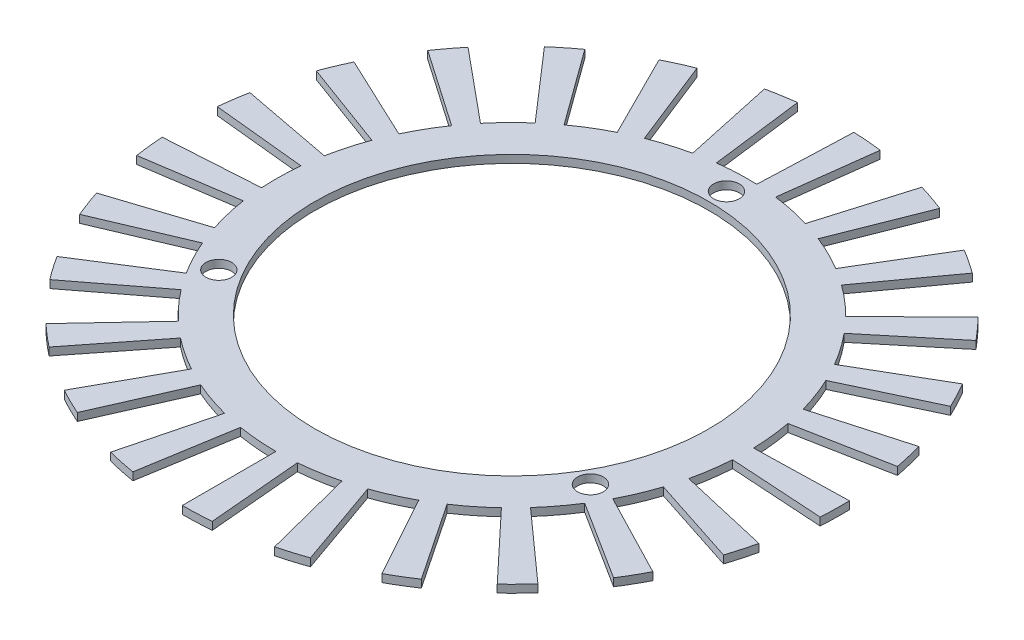
from build123d import *

# Parameters (mm, degrees)
SKETCH1_R           = 30.25
SKETCH1_R_2         = 25.25
EXTRUDE_THIN1_DEPTH = 1
SKETCH2_R           = 1.65
CUT_EXTRUDE3_DEPTH  = 10
BOSS_EXTRUDE1_DEPTH = 1


with BuildPart() as part:
    # Sketch1 → Extrude-Thin1 (new body)
    with BuildSketch(Plane(origin=(0, 0, 0), x_dir=(1, 0, 0), z_dir=(0, 1, 0))):
        Circle(SKETCH1_R)
        Circle(SKETCH1_R_2, mode=Mode.SUBTRACT)
    extrude(amount=-EXTRUDE_THIN1_DEPTH)

    # Sketch2 → Cut-Extrude3 (cut)
    with BuildSketch(Plane(origin=(0, 0, 0), x_dir=(1, 0, 0), z_dir=(0, 1, 0))):
        with Locations((0, 27.5)):
            Circle(SKETCH2_R)
        with Locations((23.815698604, -13.75)):
            Circle(SKETCH2_R)
        with Locations((-23.815698604, -13.75)):
            Circle(SKETCH2_R)
    extrude(amount=-CUT_EXTRUDE3_DEPTH, mode=Mode.SUBTRACT)

    # Sketch5 → Boss-Extrude1 (add)
    with BuildSketch(Plane.XZ.offset(1)):
        with BuildLine():
            Line((0, 42.25), (0, 30.25))
            ThreePointArc((0, 30.25), (1.319486468, 30.221208703), (2.636461218, 30.134889617))
            Line((2.636461218, 30.134889617), (3.682330131, 42.089225994))
            ThreePointArc((3.682330131, 42.089225994), (1.842919116, 42.209787362), (0, 42.25))
        make_face()
        with BuildLine():
            Line((10.507147733, 40.922638558), (7.522869087, 29.299640624))
            ThreePointArc((7.522869087, 29.299640624), (8.793741356, 28.943610918), (10.047874239, 28.532485403))
            Line((10.047874239, 28.532485403), (14.033807822, 39.851157298))
            ThreePointArc((14.033807822, 39.851157298), (12.28216768, 40.425373926), (10.507147733, 40.922638558))
        make_face()
        with BuildLine():
            Line((20.354092731, 37.023957232), (14.573048642, 26.508277071))
            ThreePointArc((14.573048642, 26.508277071), (15.715453134, 25.847379612), (16.827942369, 25.137280196))
            Line((16.827942369, 25.137280196), (23.503489755, 35.109093827))
            ThreePointArc((23.503489755, 35.109093827), (21.949682477, 36.100885573), (20.354092731, 37.023957232))
        make_face()
        with BuildLine():
            Line((28.922115225, 30.798924509), (20.707549954, 22.051300979))
            ThreePointArc((20.707549954, 22.051300979), (21.649705195, 21.127062384), (22.55064899, 20.162607225))
            Line((22.55064899, 20.162607225), (31.496360987, 28.160996868))
            ThreePointArc((31.496360987, 28.160996868), (30.238017999, 29.508045809), (28.922115225, 30.798924509))
        make_face()
        with BuildLine():
            Line((35.672854852, 22.638682088), (25.540919746, 16.208760548))
            ThreePointArc((25.540919746, 16.208760548), (26.223626655, 15.079254128), (26.8564154, 13.92104349))
            Line((26.8564154, 13.92104349), (37.510200022, 19.443440907))
            ThreePointArc((37.510200022, 19.443440907), (36.626387643, 21.061107005), (35.672854852, 22.638682088))
        make_face()
        with BuildLine():
            Line((40.182137813, 13.055968012), (28.769459618, 9.34776408))
            ThreePointArc((28.769459618, 9.34776408), (29.14982121, 8.083960876), (29.47469446, 6.804769394))
            Line((29.47469446, 6.804769394), (41.167135237, 9.504182046))
            ThreePointArc((41.167135237, 9.504182046), (40.713386648, 11.290821389), (40.182137813, 13.055968012))
        make_face()
        with BuildLine():
            Line((42.166629276, 2.65289945), (30.190308535, 1.899413216))
            ThreePointArc((30.190308535, 1.899413216), (30.244425292, 0.580722633), (30.240970066, -0.739073389))
            Line((30.240970066, -0.739073389), (42.237387943, -1.032259527))
            ThreePointArc((42.237387943, -1.032259527), (42.242213837, 0.811091941), (42.166629276, 2.65289945))
        make_face()
        with BuildLine():
            Line((41.501636343, -7.916860541), (29.714189335, -5.668284766))
            ThreePointArc((29.714189335, -5.668284766), (29.438660902, -6.95900455), (29.107094304, -8.236477473))
            Line((29.107094304, -8.236477473), (40.653710227, -11.503840437))
            ThreePointArc((40.653710227, -11.503840437), (41.116807375, -9.719601396), (41.501636343, -7.916860541))
        make_face()
        with BuildLine():
            Line((38.228942967, -17.989175069), (27.371018337, -12.87982357))
            ThreePointArc((27.371018337, -12.87982357), (26.783157179, -14.061471883), (26.144312759, -15.216353386))
            Line((26.144312759, -15.216353386), (36.515610383, -21.252592745))
            ThreePointArc((36.515610383, -21.252592745), (37.407880688, -19.639576432), (38.228942967, -17.989175069))
        make_face()
        with BuildLine():
            Line((32.554184507, -26.931163567), (23.308025594, -19.28207569))
            ThreePointArc((23.308025594, -19.28207569), (22.44476919, -20.280405224), (21.538787891, -21.240129853))
            Line((21.538787891, -21.240129853), (30.083100443, -29.665966489))
            ThreePointArc((30.083100443, -29.665966489), (31.348479281, -28.325524651), (32.554184507, -26.931163567))
        make_face()
        with BuildLine():
            Line((24.833926909, -34.180968012), (17.780503882, -24.47276408))
            ThreePointArc((17.780503882, -24.47276408), (16.696093806, -25.225046118), (15.579901766, -25.929310846))
            Line((15.579901766, -25.929310846), (21.760358665, -36.215318455))
            ThreePointArc((21.760358665, -36.215318455), (23.319337629, -35.231675982), (24.833926909, -34.180968012))
        make_face()
        with BuildLine():
            Line((15.553262351, -39.283056529), (11.135767719, -28.125738698))
            ThreePointArc((11.135767719, -28.125738698), (9.898341444, -28.584704593), (8.642073114, -28.989257878))
            Line((8.642073114, -28.989257878), (12.070333523, -40.489128771))
            ThreePointArc((12.070333523, -40.489128771), (13.824956232, -39.924091539), (15.553262351, -39.283056529))
        make_face()
        with BuildLine():
            Line((5.295329118, -41.916846131), (3.791330315, -30.011469715))
            ThreePointArc((3.791330315, -30.011469715), (2.478639886, -30.148280951), (1.161231225, -30.227703221))
            Line((1.161231225, -30.227703221), (1.621884934, -42.218858218))
            ThreePointArc((1.621884934, -42.218858218), (3.46190199, -42.107929593), (5.295329118, -41.916846131))
        make_face()
        with BuildLine():
            Line((-5.295329118, -41.916846131), (-3.791330315, -30.011469715))
            ThreePointArc((-3.791330315, -30.011469715), (-5.096803732, -29.81752994), (-6.392575093, -29.566830802))
            Line((-6.392575093, -29.566830802), (-8.92847265, -41.295821534))
            ThreePointArc((-8.92847265, -41.295821534), (-7.118676287, -41.645971569), (-5.295329118, -41.916846131))
        make_face()
        with BuildLine():
            Line((-15.553262351, -39.283056529), (-11.135767719, -28.125738698))
            ThreePointArc((-11.135767719, -28.125738698), (-12.351996427, -27.613233861), (-13.544712407, -27.048165664))
            Line((-13.544712407, -27.048165664), (-18.917821461, -37.778016506))
            ThreePointArc((-18.917821461, -37.778016506), (-17.251961951, -38.567243988), (-15.553262351, -39.283056529))
        make_face()
        with BuildLine():
            Line((-24.833926909, -34.180968012), (-17.780503882, -24.47276408))
            ThreePointArc((-17.780503882, -24.47276408), (-18.831067758, -23.673896745), (-19.845785627, -22.829964802))
            Line((-19.845785627, -22.829964802), (-27.718493975, -31.886479764))
            ThreePointArc((-27.718493975, -31.886479764), (-26.301243398, -33.065194627), (-24.833926909, -34.180968012))
        make_face()
        with BuildLine():
            Line((-32.554184507, -26.931163567), (-23.308025594, -19.28207569))
            ThreePointArc((-23.308025594, -19.28207569), (-24.126913847, -18.247041629), (-24.899875148, -17.177273288))
            Line((-24.899875148, -17.177273288), (-34.777511571, -23.991398228))
            ThreePointArc((-34.777511571, -23.991398228), (-33.697920993, -25.485537482), (-32.554184507, -26.931163567))
        make_face()
        with BuildLine():
            Line((-38.228942967, -17.989175069), (-27.371018337, -12.87982357))
            ThreePointArc((-27.371018337, -12.87982357), (-27.906777206, -11.67365778), (-28.389413938, -10.44527052))
            Line((-28.389413938, -10.44527052), (-39.651330212, -14.588848908))
            ThreePointArc((-39.651330212, -14.588848908), (-38.97723428, -16.304530288), (-38.228942967, -17.989175069))
        make_face()
        with BuildLine():
            Line((-41.501636343, -7.916860541), (-29.714189335, -5.668284766))
            ThreePointArc((-29.714189335, -5.668284766), (-29.933155119, -4.36677508), (-30.095141442, -3.05695299))
            Line((-30.095141442, -3.05695299), (-42.033709948, -4.269628556))
            ThreePointArc((-42.033709948, -4.269628556), (-41.807464588, -6.099049492), (-41.501636343, -7.916860541))
        make_face()
        with BuildLine():
            Line((-42.166629276, 2.65289945), (-30.190308535, 1.899413216))
            ThreePointArc((-30.190308535, 1.899413216), (-30.07872281, 3.214488158), (-29.909880527, 4.523444139))
            Line((-29.909880527, 4.523444139), (-41.774957099, 6.31786826))
            ThreePointArc((-41.774957099, 6.31786826), (-42.01077814, 4.489657014), (-42.166629276, 2.65289945))
        make_face()
        with BuildLine():
            Line((-40.182137813, 13.055968012), (-28.769459618, 9.34776408))
            ThreePointArc((-28.769459618, 9.34776408), (-28.334333725, 10.593773283), (-27.845271817, 11.819616637))
            Line((-27.845271817, 11.819616637), (-38.891330058, 16.508390179))
            ThreePointArc((-38.891330058, 16.508390179), (-39.574399996, 14.796261858), (-40.182137813, 13.055968012))
        make_face()
        with BuildLine():
            Line((-35.672854852, 22.638682088), (-25.540919746, 16.208760548))
            ThreePointArc((-25.540919746, 16.208760548), (-24.809594245, 17.307412672), (-24.031042271, 18.373119152))
            Line((-24.031042271, 18.373119152), (-33.564017718, 25.661629228))
            ThreePointArc((-33.564017718, 25.661629228), (-34.651416756, 24.173163153), (-35.672854852, 22.638682088))
        make_face()
        with BuildLine():
            Line((-28.922115225, 30.798924509), (-20.707549954, 22.051300979))
            ThreePointArc((-20.707549954, 22.051300979), (-19.725976716, 22.93356367), (-18.70685396, 23.772171019))
            Line((-18.70685396, 23.772171019), (-26.127754704, 33.202453737))
            ThreePointArc((-26.127754704, 33.202453737), (-27.551157562, 32.031175704), (-28.922115225, 30.798924509))
        make_face()
        with BuildLine():
            Line((-20.354092731, 37.023957232), (-14.573048642, 26.508277071))
            ThreePointArc((-14.573048642, 26.508277071), (-13.402903522, 27.118714519), (-12.207245215, 27.677529952))
            Line((-12.207245215, 27.677529952), (-17.049788771, 38.657045967))
            ThreePointArc((-17.049788771, 38.657045967), (-18.719757812, 37.876551684), (-20.354092731, 37.023957232))
        make_face()
        with BuildLine():
            Line((-10.507147733, 40.922638558), (-7.522869087, 29.299640624))
            ThreePointArc((-7.522869087, 29.299640624), (-6.237676608, 29.599896799), (-4.940610358, 29.843807889))
            Line((-4.940610358, 29.843807889), (-6.900521905, 41.682673828))
            ThreePointArc((-6.900521905, 41.682673828), (-8.712126833, 41.342004621), (-10.507147733, 40.922638558))
        make_face()
    extrude(amount=-BOSS_EXTRUDE1_DEPTH)


solid = part.part
